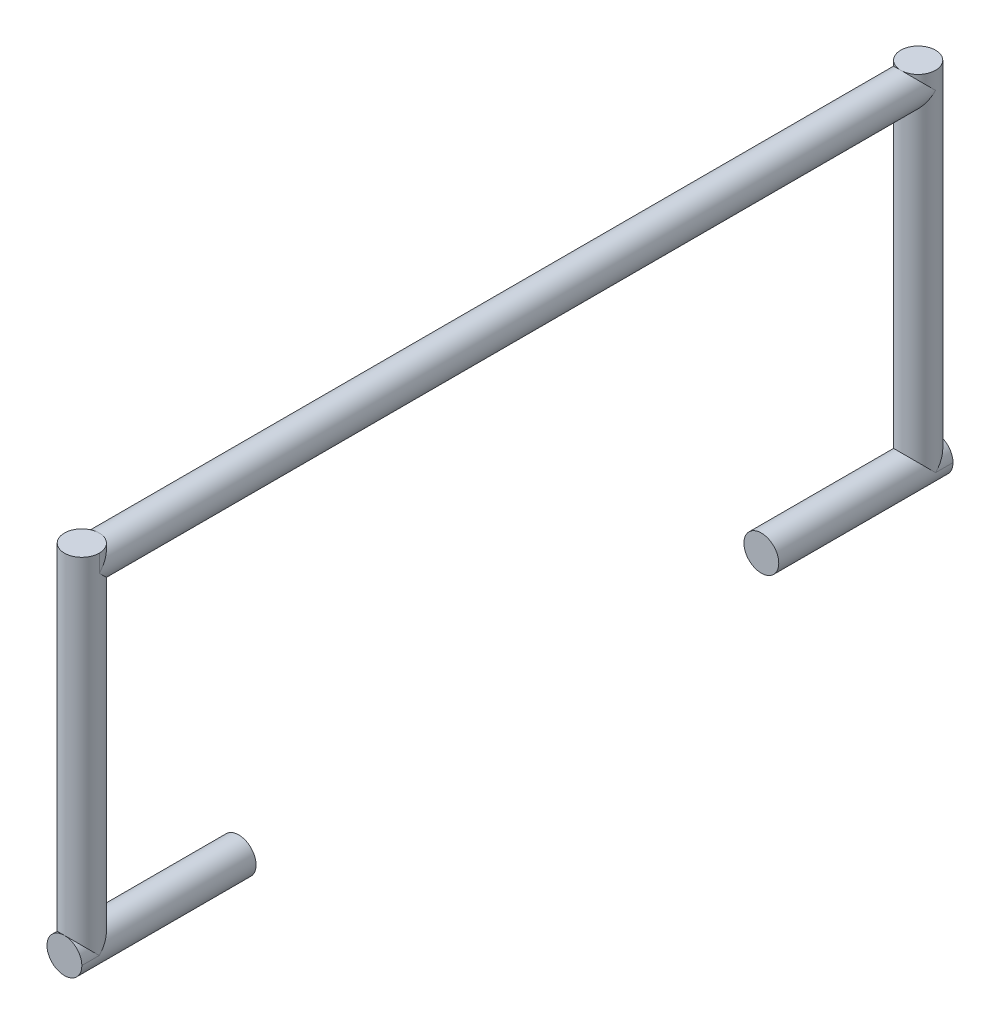
from build123d import *
from build123d.topology import SkipClean

# Parameters (mm, degrees)
SKETCH1_R           = 0.635
BOSS_EXTRUDE1_DEPTH = 15.24
SKETCH2_R           = 0.635
BOSS_EXTRUDE2_DEPTH = 12.7
SKETCH3_R           = 0.635
BOSS_EXTRUDE3_DEPTH = 6.35


with BuildPart() as part:
    # Sketch1 → Boss-Extrude1 (new, symmetric)
    with BuildSketch(Plane.XY):
        Circle(SKETCH1_R)
    extrude(amount=BOSS_EXTRUDE1_DEPTH, both=True)

    # Sketch2 → Boss-Extrude2 (add)
    with BuildSketch(Plane(origin=(0, 0.635, 0), x_dir=(1, 0, 0), z_dir=(0, 1, 0))):
        with Locations((0, -15.24)):
            Circle(SKETCH2_R)
    boss_extrude2 = extrude(amount=-BOSS_EXTRUDE2_DEPTH)

    # Sketch3 → Boss-Extrude3 (add)
    with SkipClean():  # the faces are left unmerged after this step: merging them gives an invalid solid
        with BuildSketch(Plane.XY.offset(15.875)):
            with Locations((0, -12.065)):
                Circle(SKETCH3_R)
        boss_extrude3 = extrude(amount=-BOSS_EXTRUDE3_DEPTH)

    # Mirror1: Boss-Extrude2, Boss-Extrude3 across plane
    with SkipClean():  # the faces are left unmerged after this step: merging them gives an invalid solid
        add(boss_extrude2.mirror(Plane.XY))
        add(boss_extrude3.mirror(Plane.XY))


solid = part.part
